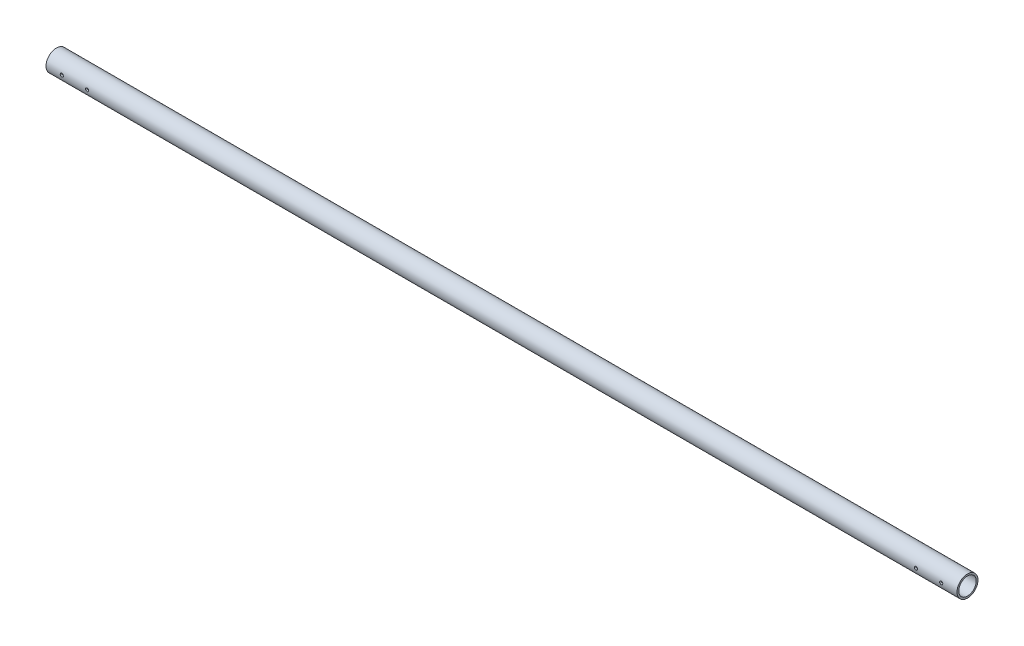
from build123d import *

# Parameters (mm, degrees)
BOSS_EXTRUDE1_DEPTH      = 914.4
BOSS_EXTRUDE1_DEPTH_BACK = 914.4
SKETCH1_R                = 21.082
SKETCH1_R_2              = 17.526
SKETCH2_R                = 3.175
CUT_EXTRUDE1_DEPTH       = 915.885928107


with BuildPart() as part:
    # Sketch1 → Boss-Extrude1 (new, two sides: drawn at the far end of the back side and taken through both)
    with BuildSketch(Plane(origin=(0, 0, 0), x_dir=(0, 0, -1), z_dir=(1, 0, 0)).offset(-BOSS_EXTRUDE1_DEPTH_BACK)):
        Circle(SKETCH1_R)
        Circle(SKETCH1_R_2, mode=Mode.SUBTRACT)
    extrude(amount=BOSS_EXTRUDE1_DEPTH + BOSS_EXTRUDE1_DEPTH_BACK)

    # Sketch2 → Cut-Extrude1 (cut, symmetric)
    with BuildSketch(Plane.XY):
        with Locations((-831.85, 0)):
            Circle(SKETCH2_R)
        with Locations((-882.65, 0)):
            Circle(SKETCH2_R)
    cut_extrude1 = extrude(amount=CUT_EXTRUDE1_DEPTH, both=True, mode=Mode.SUBTRACT)

    # Mirror1: Cut-Extrude1 across plane
    add(cut_extrude1.mirror(Plane(origin=(0, 0, 0), x_dir=(0, 0, 1), z_dir=(1, 0, 0))), mode=Mode.SUBTRACT)


solid = part.part
